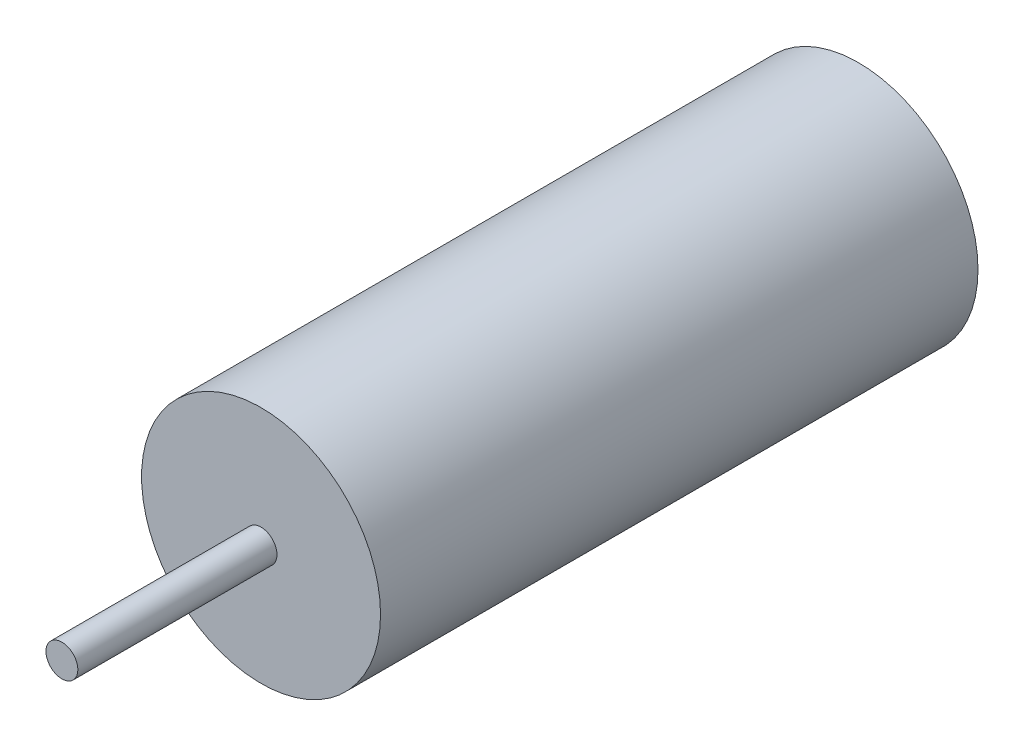
from build123d import *

# Parameters (mm, degrees)
SKETCH1_R           = 3
BOSS_EXTRUDE1_DEPTH = 15
SKETCH2_R           = 0.4
BOSS_EXTRUDE2_DEPTH = 5


with BuildPart() as part:
    # Sketch1 → Boss-Extrude1 (new body)
    with BuildSketch(Plane.XY):
        Circle(SKETCH1_R)
    extrude(amount=BOSS_EXTRUDE1_DEPTH)

    # Sketch2 → Boss-Extrude2 (add)
    with BuildSketch(Plane.XY.offset(15)):
        Circle(SKETCH2_R)
    extrude(amount=BOSS_EXTRUDE2_DEPTH)


solid = part.part
